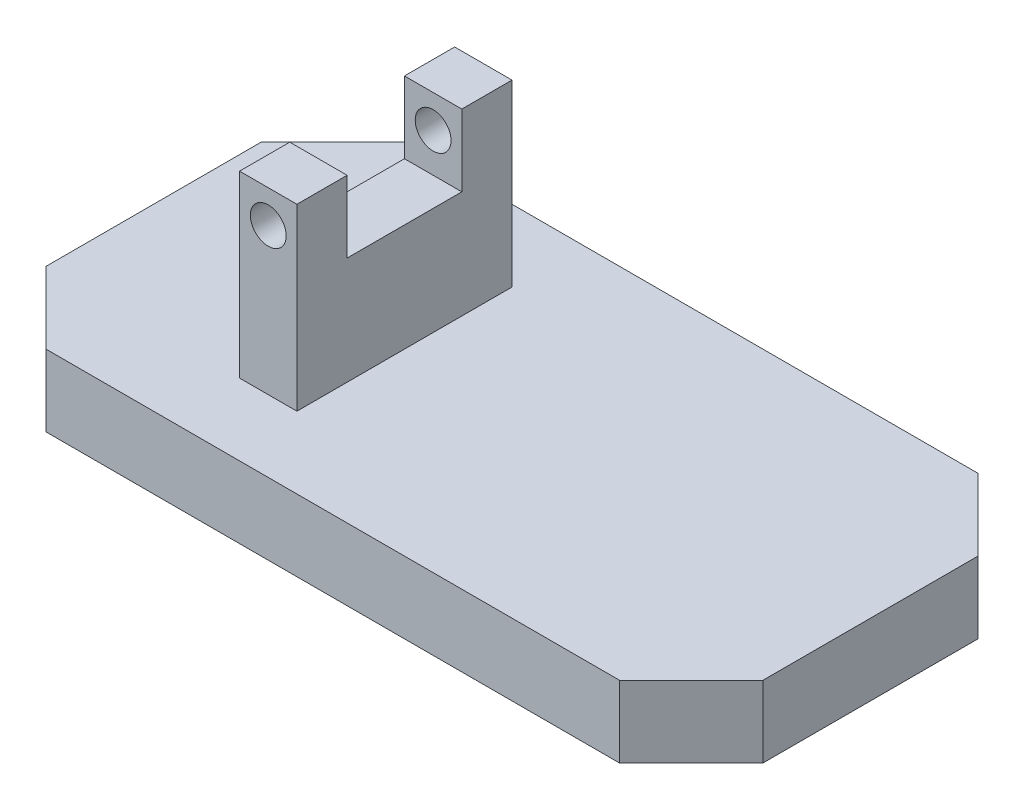
from build123d import *

# Parameters (mm, degrees)
SKETCH1_W           = 100
SKETCH1_H           = 50
BOSS_EXTRUDE1_DEPTH = 10
CHAMFER1_SIZE       = 10
SKETCH2_W           = 8
SKETCH2_H           = 30
BOSS_EXTRUDE2_DEPTH = 25
SKETCH3_W           = 24.32534271
SKETCH3_H           = 16
CUT_EXTRUDE1_DEPTH  = 10
SKETCH4_R           = 2.5
CUT_EXTRUDE2_DEPTH  = 42


with BuildPart() as part:
    # Sketch1 → Boss-Extrude1 (new body)
    with BuildSketch(Plane(origin=(0, 0, 0), x_dir=(1, 0, 0), z_dir=(0, 1, 0))):
        Rectangle(SKETCH1_W, SKETCH1_H)
    extrude(amount=BOSS_EXTRUDE1_DEPTH)

    # Chamfer1
    chamfer1_edges = [part.edges().sort_by_distance(p)[0] for p in [
        (-50, 5, -25),
        (50, 5, -25),
        (50, 5, 25),
        (-50, 5, 25),
    ]]
    chamfer(chamfer1_edges, length=CHAMFER1_SIZE)

    # Sketch2 → Boss-Extrude2 (add)
    with BuildSketch(Plane(origin=(0, 10, 0), x_dir=(1, 0, 0), z_dir=(0, 1, 0))):
        with Locations((-19, 0)):
            Rectangle(SKETCH2_W, SKETCH2_H)
    extrude(amount=BOSS_EXTRUDE2_DEPTH)

    # Sketch3 → Cut-Extrude1 (cut)
    with BuildSketch(Plane(origin=(0, 35, 0), x_dir=(1, 0, 0), z_dir=(0, 1, 0))):
        with Locations((-18.085363493, 0)):
            Rectangle(SKETCH3_W, SKETCH3_H)
    extrude(amount=-CUT_EXTRUDE1_DEPTH, mode=Mode.SUBTRACT)

    # Sketch4 → Cut-Extrude2 (cut)
    with BuildSketch(Plane.XY.offset(15)):
        with Locations((-19, 30.428638458)):
            Circle(SKETCH4_R)
    extrude(amount=-CUT_EXTRUDE2_DEPTH, mode=Mode.SUBTRACT)


solid = part.part
